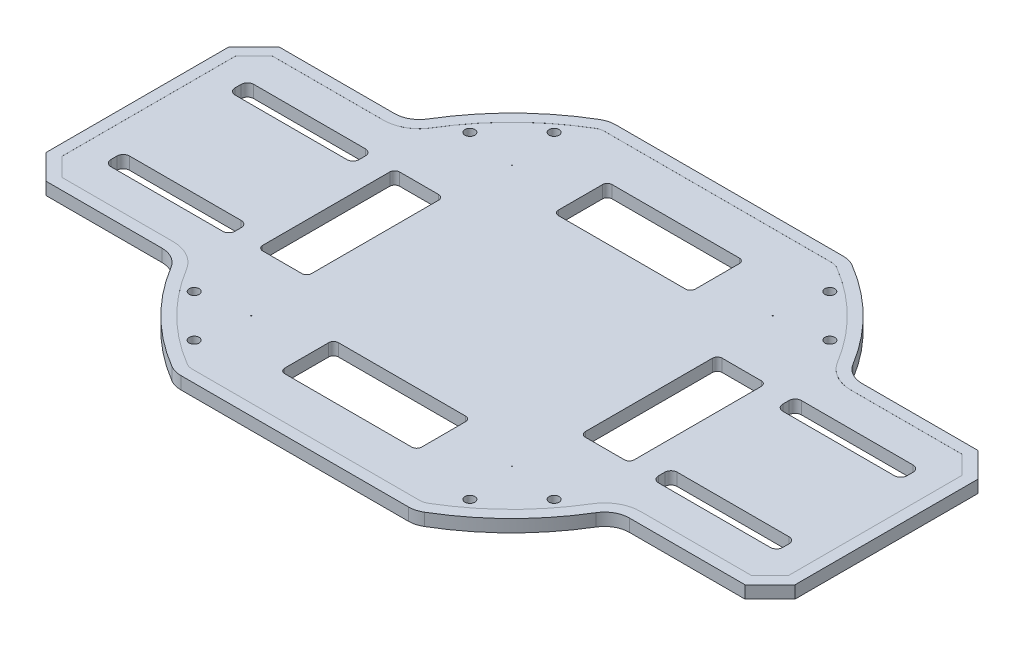
from build123d import *

# Parameters (mm, degrees)
SKETCH1_R           = 1.016
SKETCH1_R_2         = 0.080960088
BOSS_EXTRUDE1_DEPTH = 2.54
SKETCH3_W           = 28
SKETCH3_H           = 11
SKETCH3_W_2         = 10
SKETCH3_H_2         = 28
CUT_EXTRUDE_1_DEPTH = 10
CUT_EXTRUDE2_DEPTH  = 2.54
FILLET_1_R          = 1
BOSS_EXTRUDE2_DEPTH = 0.01


with BuildPart() as part:
    # Sketch1 → Boss-Extrude1 (new body)
    with BuildSketch(Plane(origin=(0, 0, 0), x_dir=(1, 0, 0), z_dir=(0, 1, 0))):
        with BuildLine():
            Line((-23.244816627, 44.45), (23.244816627, 44.45))
            ThreePointArc((23.244816627, 44.45), (24.583514169, 44.270437622), (25.827574029, 43.744444444))
            ThreePointArc((25.827574029, 43.744444444), (35.740062311, 36.101079569), (43.482663438, 26.265909091))
            ThreePointArc((43.482663438, 26.265909091), (45.334600658, 24.468164919), (47.830929781, 23.8125))
            Line((47.830929781, 23.8125), (71.516875, 23.8125))
            Line((71.516875, 23.8125), (76.596875, 18.7325))
            Line((76.596875, 18.7325), (76.596875, -18.7325))
            Line((76.596875, -18.7325), (71.516875, -23.8125))
            Line((71.516875, -23.8125), (47.830929781, -23.8125))
            ThreePointArc((47.830929781, -23.8125), (45.334600658, -24.468164919), (43.482663438, -26.265909091))
            ThreePointArc((43.482663438, -26.265909091), (35.740062311, -36.101079569), (25.827574029, -43.744444444))
            ThreePointArc((25.827574029, -43.744444444), (24.583514169, -44.270437622), (23.244816627, -44.45))
            Line((23.244816627, -44.45), (-23.244816627, -44.45))
            ThreePointArc((-23.244816627, -44.45), (-24.583514169, -44.270437622), (-25.827574029, -43.744444444))
            ThreePointArc((-25.827574029, -43.744444444), (-35.740062311, -36.101079569), (-43.482663438, -26.265909091))
            ThreePointArc((-43.482663438, -26.265909091), (-45.334600658, -24.468164919), (-47.830929781, -23.8125))
            Line((-47.830929781, -23.8125), (-71.516875, -23.8125))
            Line((-71.516875, -23.8125), (-76.596875, -18.7325))
            Line((-76.596875, -18.7325), (-76.596875, 18.7325))
            Line((-76.596875, 18.7325), (-71.516875, 23.8125))
            Line((-71.516875, 23.8125), (-47.830929781, 23.8125))
            ThreePointArc((-47.830929781, 23.8125), (-45.334600658, 24.468164919), (-43.482663438, 26.265909091))
            ThreePointArc((-43.482663438, 26.265909091), (-35.740062311, 36.101079569), (-25.827574029, 43.744444444))
            ThreePointArc((-25.827574029, 43.744444444), (-24.583514169, 44.270437622), (-23.244816627, 44.45))
        make_face()
        with Locations((36.819050096, 28.19800422)):
            Circle(SKETCH1_R, mode=Mode.SUBTRACT)
        with Locations((28.19800422, 36.819050096)):
            Circle(SKETCH1_R, mode=Mode.SUBTRACT)
        with Locations((26.671582547, 26.671582547)):
            Circle(SKETCH1_R_2, mode=Mode.SUBTRACT)
        with Locations((26.671582547, -26.671582547)):
            Circle(SKETCH1_R_2, mode=Mode.SUBTRACT)
        with Locations((36.819050096, -28.19800422)):
            Circle(SKETCH1_R, mode=Mode.SUBTRACT)
        with Locations((28.19800422, -36.819050096)):
            Circle(SKETCH1_R, mode=Mode.SUBTRACT)
        with Locations((-26.671582547, -26.671582547)):
            Circle(SKETCH1_R_2, mode=Mode.SUBTRACT)
        with Locations((-28.19800422, -36.819050096)):
            Circle(SKETCH1_R, mode=Mode.SUBTRACT)
        with Locations((-36.819050096, -28.19800422)):
            Circle(SKETCH1_R, mode=Mode.SUBTRACT)
        with Locations((-26.671582547, 26.671582547)):
            Circle(SKETCH1_R_2, mode=Mode.SUBTRACT)
        with Locations((-36.819050096, 28.19800422)):
            Circle(SKETCH1_R, mode=Mode.SUBTRACT)
        with Locations((-28.19800422, 36.819050096)):
            Circle(SKETCH1_R, mode=Mode.SUBTRACT)
    extrude(amount=BOSS_EXTRUDE1_DEPTH)

    # Sketch3 → 切除-拉伸1 (cut)
    with BuildSketch(Plane(origin=(0, 2.54, 0), x_dir=(1, 0, 0), z_dir=(0, 1, 0))):
        with Locations((0, 28)):
            Rectangle(SKETCH3_W, SKETCH3_H)
        with Locations((0, -28)):
            Rectangle(SKETCH3_W, SKETCH3_H)
        with Locations((-33, 0)):
            Rectangle(SKETCH3_W_2, SKETCH3_H_2)
        with Locations((33, 0)):
            Rectangle(SKETCH3_W_2, SKETCH3_H_2)
    extrude(amount=-CUT_EXTRUDE_1_DEPTH, mode=Mode.SUBTRACT)

    # Sketch4 → Cut-Extrude2 (cut)
    with BuildSketch(Plane(origin=(0, 2.54, 0), x_dir=(1, 0, 0), z_dir=(0, 1, 0))):
        with BuildLine():
            Line((44.592875, 14.605), (67.452875, 14.605))
            ThreePointArc((67.452875, 14.605), (68.350900612, 14.233025612), (68.722875, 13.335))
            Line((68.722875, 13.335), (68.722875, 12.065))
            ThreePointArc((68.722875, 12.065), (68.350900612, 11.166974388), (67.452875, 10.795))
            Line((67.452875, 10.795), (44.592875, 10.795))
            ThreePointArc((44.592875, 10.795), (43.694849388, 11.166974388), (43.322875, 12.065))
            Line((43.322875, 12.065), (43.322875, 13.335))
            ThreePointArc((43.322875, 13.335), (43.694849388, 14.233025612), (44.592875, 14.605))
        make_face()
        with BuildLine():
            Line((68.722875, -13.335), (68.722875, -12.065))
            ThreePointArc((68.722875, -12.065), (68.350900612, -11.166974388), (67.452875, -10.795))
            Line((67.452875, -10.795), (44.592875, -10.795))
            ThreePointArc((44.592875, -10.795), (43.694849388, -11.166974388), (43.322875, -12.065))
            Line((43.322875, -12.065), (43.322875, -13.335))
            ThreePointArc((43.322875, -13.335), (43.694849388, -14.233025612), (44.592875, -14.605))
            Line((44.592875, -14.605), (67.452875, -14.605))
            ThreePointArc((67.452875, -14.605), (68.350900612, -14.233025612), (68.722875, -13.335))
        make_face()
        with BuildLine():
            Line((-44.592875, -14.605), (-67.452875, -14.605))
            ThreePointArc((-67.452875, -14.605), (-68.350900612, -14.233025612), (-68.722875, -13.335))
            Line((-68.722875, -13.335), (-68.722875, -12.065))
            ThreePointArc((-68.722875, -12.065), (-68.350900612, -11.166974388), (-67.452875, -10.795))
            Line((-67.452875, -10.795), (-44.592875, -10.795))
            ThreePointArc((-44.592875, -10.795), (-43.694849388, -11.166974388), (-43.322875, -12.065))
            Line((-43.322875, -12.065), (-43.322875, -13.335))
            ThreePointArc((-43.322875, -13.335), (-43.694849388, -14.233025612), (-44.592875, -14.605))
        make_face()
        with BuildLine():
            Line((-68.722875, 13.335), (-68.722875, 12.065))
            ThreePointArc((-68.722875, 12.065), (-68.350900612, 11.166974388), (-67.452875, 10.795))
            Line((-67.452875, 10.795), (-44.592875, 10.795))
            ThreePointArc((-44.592875, 10.795), (-43.694849388, 11.166974388), (-43.322875, 12.065))
            Line((-43.322875, 12.065), (-43.322875, 13.335))
            ThreePointArc((-43.322875, 13.335), (-43.694849388, 14.233025612), (-44.592875, 14.605))
            Line((-44.592875, 14.605), (-67.452875, 14.605))
            ThreePointArc((-67.452875, 14.605), (-68.350900612, 14.233025612), (-68.722875, 13.335))
        make_face()
    extrude(amount=-CUT_EXTRUDE2_DEPTH, mode=Mode.SUBTRACT)

    # 圆角1
    fillet_1_edges = [part.edges().sort_by_distance(p)[0] for p in [
        (14, 1.27, -33.5),
        (14, 1.27, -22.5),
        (-14, 1.27, -22.5),
        (-14, 1.27, -33.5),
        (14, 1.27, 33.5),
        (-14, 1.27, 33.5),
        (-14, 1.27, 22.5),
        (14, 1.27, 22.5),
        (-28, 1.27, -14),
        (-28, 1.27, 14),
        (-38, 1.27, 14),
        (-38, 1.27, -14),
        (38, 1.27, 14),
        (28, 1.27, 14),
        (28, 1.27, -14),
        (38, 1.27, -14),
    ]]
    fillet(fillet_1_edges, radius=FILLET_1_R)

    # Sketch8 → Boss-Extrude2 (add)
    with BuildSketch(Plane(origin=(0, 2.54, 0), x_dir=(1, 0, 0), z_dir=(0, 1, 0))):
        with BuildLine():
            Line((47.830929781, -23.8125), (71.516875, -23.8125))
            Line((71.516875, -23.8125), (76.596875, -18.7325))
            Line((76.596875, -18.7325), (76.596875, 18.7325))
            Line((76.596875, 18.7325), (71.516875, 23.8125))
            Line((71.516875, 23.8125), (47.830929781, 23.8125))
            ThreePointArc((47.830929781, 23.8125), (45.334600658, 24.468164919), (43.482663438, 26.265909091))
            ThreePointArc((43.482663438, 26.265909091), (35.740062311, 36.101079569), (25.827574029, 43.744444444))
            ThreePointArc((25.827574029, 43.744444444), (24.583514169, 44.270437622), (23.244816627, 44.45))
            Line((23.244816627, 44.45), (-23.244816627, 44.45))
            ThreePointArc((-23.244816627, 44.45), (-24.583514169, 44.270437622), (-25.827574029, 43.744444444))
            ThreePointArc((-25.827574029, 43.744444444), (-35.740062311, 36.101079569), (-43.482663438, 26.265909091))
            ThreePointArc((-43.482663438, 26.265909091), (-45.334600658, 24.468164919), (-47.830929781, 23.8125))
            Line((-47.830929781, 23.8125), (-71.516875, 23.8125))
            Line((-71.516875, 23.8125), (-76.596875, 18.7325))
            Line((-76.596875, 18.7325), (-76.596875, -18.7325))
            Line((-76.596875, -18.7325), (-71.516875, -23.8125))
            Line((-71.516875, -23.8125), (-47.830929781, -23.8125))
            ThreePointArc((-47.830929781, -23.8125), (-45.334600658, -24.468164919), (-43.482663438, -26.265909091))
            ThreePointArc((-43.482663438, -26.265909091), (-35.740062311, -36.101079569), (-25.827574029, -43.744444444))
            ThreePointArc((-25.827574029, -43.744444444), (-24.583514169, -44.270437622), (-23.244816627, -44.45))
            Line((-23.244816627, -44.45), (23.244816627, -44.45))
            ThreePointArc((23.244816627, -44.45), (24.583514169, -44.270437622), (25.827574029, -43.744444444))
            ThreePointArc((25.827574029, -43.744444444), (35.740062311, -36.101079569), (43.482663438, -26.265909091))
            ThreePointArc((43.482663438, -26.265909091), (45.334600658, -24.468164919), (47.830929781, -23.8125))
        make_face()
        with BuildLine():
            Line((47.830929781, -21.5125), (70.564183807, -21.5125))
            Line((70.564183807, -21.5125), (74.296875, -17.779808807))
            Line((74.296875, -17.779808807), (74.296875, 17.779808807))
            Line((74.296875, 17.779808807), (70.564183807, 21.5125))
            Line((70.564183807, 21.5125), (47.830929781, 21.5125))
            ThreePointArc((47.830929781, 21.5125), (44.204372906, 22.465021083), (41.513960172, 25.076704545))
            ThreePointArc((41.513960172, 25.076704545), (34.121909883, 34.466581872), (24.658215363, 41.763888889))
            ThreePointArc((24.658215363, 41.763888889), (23.977410951, 42.051735549), (23.244816627, 42.15))
            Line((23.244816627, 42.15), (-23.244816627, 42.15))
            ThreePointArc((-23.244816627, 42.15), (-23.977410951, 42.051735549), (-24.658215363, 41.763888889))
            ThreePointArc((-24.658215363, 41.763888889), (-34.121909883, 34.466581872), (-41.513960172, 25.076704545))
            ThreePointArc((-41.513960172, 25.076704545), (-44.204372906, 22.465021083), (-47.830929781, 21.5125))
            Line((-47.830929781, 21.5125), (-70.564183807, 21.5125))
            Line((-70.564183807, 21.5125), (-74.296875, 17.779808807))
            Line((-74.296875, 17.779808807), (-74.296875, -17.779808807))
            Line((-74.296875, -17.779808807), (-70.564183807, -21.5125))
            Line((-70.564183807, -21.5125), (-47.830929781, -21.5125))
            ThreePointArc((-47.830929781, -21.5125), (-44.204372906, -22.465021083), (-41.513960172, -25.076704545))
            ThreePointArc((-41.513960172, -25.076704545), (-34.121909883, -34.466581872), (-24.658215363, -41.763888889))
            ThreePointArc((-24.658215363, -41.763888889), (-23.977410951, -42.051735549), (-23.244816627, -42.15))
            Line((-23.244816627, -42.15), (23.244816627, -42.15))
            ThreePointArc((23.244816627, -42.15), (23.977410951, -42.051735549), (24.658215363, -41.763888889))
            ThreePointArc((24.658215363, -41.763888889), (34.121909883, -34.466581872), (41.513960172, -25.076704545))
            ThreePointArc((41.513960172, -25.076704545), (44.204372906, -22.465021083), (47.830929781, -21.5125))
        make_face(mode=Mode.SUBTRACT)
    extrude(amount=BOSS_EXTRUDE2_DEPTH)


solid = part.part
